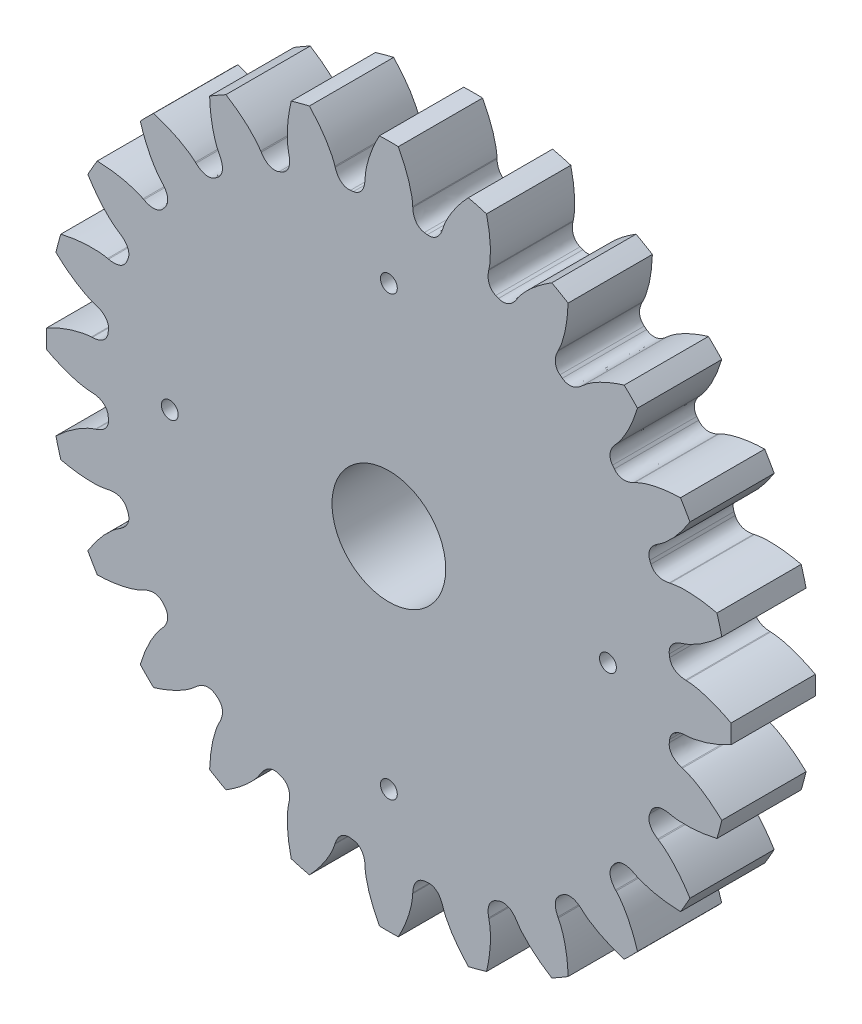
from build123d import *

# Parameters (mm, degrees)
BOSS_EXTRUDE1_DEPTH = 2.54
SKETCH2_R           = 0.254
SKETCH2_R_2         = 1.7145
CUT_EXTRUDE1_DEPTH  = 3.5400001


with BuildPart() as part:
    # Sketch1 → Boss-Extrude1 (new body)
    with BuildSketch(Plane.XY):
        with BuildLine():
            Line((3.016256703, 8.478973751), (3.010500812, 8.452042106))
            add(Edge.make_bspline(
                [(3.010500812, 8.452042106), (3.004237174, 8.425648336), (2.99688827, 8.381281904), (2.991380055, 8.318580234), (2.990974755, 8.26398578), (2.99590325, 8.207108487), (3.008355394, 8.146471227), (3.032122741, 8.081048479), (3.089990682, 7.983054513), (3.163339405, 7.924703305), (3.223040797, 7.900689665)],
                knots=[0, 0, 0, 0, 0.126202457, 0.208952284, 0.292707643, 0.37994875, 0.474167945, 0.579987459, 0.702457265, 1, 1, 1, 1], degree=3))
            ThreePointArc((3.223040797, 7.900689665), (3.265365975, 7.883290824), (3.307597234, 7.865665242))
            add(Edge.make_bspline(
                [(3.307597234, 7.865665242), (3.366792702, 7.84043019), (3.459918616, 7.829825346), (3.570129627, 7.85819873), (3.633196548, 7.887653546), (3.684878561, 7.921725569), (3.728581853, 7.958458917), (3.766899371, 7.997349615), (3.807341251, 8.045581287), (3.833516597, 8.082149552), (3.847750749, 8.105241827)],
                knots=[0, 0, 0, 0, 0.297542735, 0.420012541, 0.525832055, 0.62005125, 0.707292357, 0.791047716, 0.873797543, 1, 1, 1, 1], degree=3))
            Line((3.847750749, 8.105241827), (3.862724269, 8.128355406))
            add(Edge.make_bspline(
                [(3.862724269, 8.128355406), (3.891358957, 8.174937626), (3.947521117, 8.253427702), (4.041920253, 8.3671518), (4.146875377, 8.479989749), (4.278799081, 8.606717556), (4.439552178, 8.744566884), (4.630744241, 8.890618724), (4.792469065, 9.000256315), (4.889939742, 9.0615476), (4.91151267, 9.074890901)],
                knots=[0.278297263, 0.278297263, 0.278297263, 0.278297263, 0.361423458, 0.424900383, 0.502986534, 0.595681913, 0.702986522, 0.82490036, 0.96142343, 1, 1, 1, 1], degree=3))
            ThreePointArc((4.91151267, 9.074890901), (5.159375, 8.936299635), (5.403329722, 8.790940193))
            add(Edge.make_bspline(
                [(5.403329722, 8.790940193), (5.402560548, 8.76558584), (5.398216077, 8.650528115), (5.38412955, 8.455651513), (5.353240977, 8.21704841), (5.314236506, 8.00890748), (5.270448858, 7.831294297), (5.22520589, 7.683981519), (5.1739175, 7.545367421), (5.13402418, 7.457484525), (5.108000138, 7.409395047)],
                knots=[0, 0, 0, 0, 0.03857657, 0.17509964, 0.297013478, 0.404318087, 0.497013466, 0.575099617, 0.638576542, 0.721702737, 0.721702737, 0.721702737, 0.721702737], degree=3))
            Line((5.108000138, 7.409395047), (5.095469951, 7.384870809))
            add(Edge.make_bspline(
                [(5.095469951, 7.384870809), (5.082588531, 7.360997535), (5.064007157, 7.320044888), (5.042458244, 7.260905357), (5.02793667, 7.208276063), (5.017976304, 7.152061229), (5.014310073, 7.090267281), (5.020334915, 7.020922317), (5.050868348, 6.91129009), (5.106615371, 6.835943104), (5.1580673, 6.797295851)],
                knots=[0, 0, 0, 0, 0.126202457, 0.208952284, 0.292707643, 0.37994875, 0.474167945, 0.579987459, 0.702457265, 1, 1, 1, 1], degree=3))
            ThreePointArc((5.1580673, 6.797295851), (5.194447131, 6.769535299), (5.230677558, 6.74158004))
            add(Edge.make_bspline(
                [(5.230677558, 6.74158004), (5.281324677, 6.701883938), (5.368532668, 6.667537684), (5.482331902, 6.666419561), (5.550873337, 6.678547808), (5.609612816, 6.698082566), (5.661334245, 6.72225301), (5.708411779, 6.749901237), (5.75995891, 6.786022326), (5.794706916, 6.81456988), (5.814432772, 6.833191234)],
                knots=[0, 0, 0, 0, 0.297542735, 0.420012541, 0.525832055, 0.62005125, 0.707292357, 0.791047716, 0.873797543, 1, 1, 1, 1], degree=3))
            Line((5.814432772, 6.833191234), (5.834878315, 6.851641805))
            add(Edge.make_bspline(
                [(5.834878315, 6.851641805), (5.874593666, 6.889225572), (5.949156874, 6.950505327), (6.069773399, 7.035922076), (6.200356874, 7.11775078), (6.360584957, 7.206016074), (6.551538557, 7.297562337), (6.774016906, 7.389153435), (6.958607387, 7.453197751), (7.068620183, 7.487173318), (7.092911531, 7.494478473)],
                knots=[0.278297263, 0.278297263, 0.278297263, 0.278297263, 0.361423458, 0.424900383, 0.502986534, 0.595681913, 0.702986522, 0.82490036, 0.96142343, 1, 1, 1, 1], degree=3))
            ThreePointArc((7.092911531, 7.494478473), (7.296458098, 7.296458098), (7.494478473, 7.092911531))
            add(Edge.make_bspline(
                [(7.494478473, 7.092911531), (7.487173318, 7.068620183), (7.453197751, 6.958607387), (7.389153435, 6.774016906), (7.297562337, 6.551538557), (7.206016074, 6.360584957), (7.11775078, 6.200356874), (7.035922076, 6.069773399), (6.950505327, 5.949156874), (6.889225572, 5.874593666), (6.851641805, 5.834878315)],
                knots=[0, 0, 0, 0, 0.03857657, 0.17509964, 0.297013478, 0.404318087, 0.497013466, 0.575099617, 0.638576542, 0.721702737, 0.721702737, 0.721702737, 0.721702737], degree=3))
            Line((6.851641805, 5.834878315), (6.833191234, 5.814432772))
            add(Edge.make_bspline(
                [(6.833191234, 5.814432772), (6.81456988, 5.794706916), (6.786022326, 5.75995891), (6.749901237, 5.708411779), (6.72225301, 5.661334245), (6.698082566, 5.609612816), (6.678547808, 5.550873337), (6.666419561, 5.482331902), (6.667537684, 5.368532668), (6.701883938, 5.281324677), (6.74158004, 5.230677558)],
                knots=[0, 0, 0, 0, 0.126202457, 0.208952284, 0.292707643, 0.37994875, 0.474167945, 0.579987459, 0.702457265, 1, 1, 1, 1], degree=3))
            ThreePointArc((6.74158004, 5.230677558), (6.769535299, 5.194447131), (6.797295851, 5.1580673))
            add(Edge.make_bspline(
                [(6.797295851, 5.1580673), (6.835943104, 5.106615371), (6.91129009, 5.050868348), (7.020922317, 5.020334915), (7.090267281, 5.014310073), (7.152061229, 5.017976304), (7.208276063, 5.02793667), (7.260905357, 5.042458244), (7.320044888, 5.064007157), (7.360997535, 5.082588531), (7.384870809, 5.095469951)],
                knots=[0, 0, 0, 0, 0.297542735, 0.420012541, 0.525832055, 0.62005125, 0.707292357, 0.791047716, 0.873797543, 1, 1, 1, 1], degree=3))
            Line((7.384870809, 5.095469951), (7.409395047, 5.108000138))
            add(Edge.make_bspline(
                [(7.409395047, 5.108000138), (7.457484525, 5.13402418), (7.545367421, 5.1739175), (7.683981519, 5.22520589), (7.831294297, 5.270448858), (8.00890748, 5.314236506), (8.21704841, 5.353240977), (8.455651513, 5.38412955), (8.650528115, 5.398216077), (8.76558584, 5.402560548), (8.790940193, 5.403329722)],
                knots=[0.278297263, 0.278297263, 0.278297263, 0.278297263, 0.361423458, 0.424900383, 0.502986534, 0.595681913, 0.702986522, 0.82490036, 0.96142343, 1, 1, 1, 1], degree=3))
            ThreePointArc((8.790940193, 5.403329722), (8.936299635, 5.159375), (9.074890901, 4.91151267))
            add(Edge.make_bspline(
                [(9.074890901, 4.91151267), (9.0615476, 4.889939742), (9.000256315, 4.792469065), (8.890618724, 4.630744241), (8.744566884, 4.439552178), (8.606717556, 4.278799081), (8.479989749, 4.146875377), (8.3671518, 4.041920253), (8.253427702, 3.947521117), (8.174937626, 3.891358957), (8.128355406, 3.862724269)],
                knots=[0, 0, 0, 0, 0.03857657, 0.17509964, 0.297013478, 0.404318087, 0.497013466, 0.575099617, 0.638576542, 0.721702737, 0.721702737, 0.721702737, 0.721702737], degree=3))
            Line((8.128355406, 3.862724269), (8.105241827, 3.847750749))
            add(Edge.make_bspline(
                [(8.105241827, 3.847750749), (8.082149552, 3.833516597), (8.045581287, 3.807341251), (7.997349615, 3.766899371), (7.958458917, 3.728581853), (7.921725569, 3.684878561), (7.887653546, 3.633196548), (7.85819873, 3.570129627), (7.829825346, 3.459918616), (7.84043019, 3.366792702), (7.865665242, 3.307597234)],
                knots=[0, 0, 0, 0, 0.126202457, 0.208952284, 0.292707643, 0.37994875, 0.474167945, 0.579987459, 0.702457265, 1, 1, 1, 1], degree=3))
            ThreePointArc((7.865665242, 3.307597234), (7.883290824, 3.265365975), (7.900689665, 3.223040797))
            add(Edge.make_bspline(
                [(7.900689665, 3.223040797), (7.924703305, 3.163339405), (7.983054513, 3.089990682), (8.081048479, 3.032122741), (8.146471227, 3.008355394), (8.207108487, 2.99590325), (8.26398578, 2.990974755), (8.318580234, 2.991380055), (8.381281904, 2.99688827), (8.425648336, 3.004237174), (8.452042106, 3.010500812)],
                knots=[0, 0, 0, 0, 0.297542735, 0.420012541, 0.525832055, 0.62005125, 0.707292357, 0.791047716, 0.873797543, 1, 1, 1, 1], degree=3))
            Line((8.452042106, 3.010500812), (8.478973751, 3.016256703))
            add(Edge.make_bspline(
                [(8.478973751, 3.016256703), (8.532160138, 3.028947525), (8.627373647, 3.044735745), (8.774538997, 3.058400557), (8.928541956, 3.063974556), (9.111436193, 3.060300502), (9.322579993, 3.044105091), (9.561047444, 3.012186134), (9.752929647, 2.975354898), (9.865191307, 2.949772205), (9.889880809, 2.94395298)],
                knots=[0.278297263, 0.278297263, 0.278297263, 0.278297263, 0.361423458, 0.424900383, 0.502986534, 0.595681913, 0.702986522, 0.82490036, 0.96142343, 1, 1, 1, 1], degree=3))
            ThreePointArc((9.889880809, 2.94395298), (9.96714712, 2.670689022), (10.036864511, 2.395402336))
            add(Edge.make_bspline(
                [(10.036864511, 2.395402336), (10.018392388, 2.378017989), (9.933962285, 2.299731897), (9.78620304, 2.171894009), (9.595643648, 2.025017655), (9.420885459, 1.905420119), (9.26433143, 1.810791176), (9.128173957, 1.738616921), (8.993892619, 1.67686832), (8.903541191, 1.642934566), (8.851135018, 1.627331947)],
                knots=[0, 0, 0, 0, 0.03857657, 0.17509964, 0.297013478, 0.404318087, 0.497013466, 0.575099617, 0.638576542, 0.721702737, 0.721702737, 0.721702737, 0.721702737], degree=3))
            Line((8.851135018, 1.627331947), (8.824933583, 1.618850872))
            add(Edge.make_bspline(
                [(8.824933583, 1.618850872), (8.798944089, 1.611078457), (8.75684718, 1.595259578), (8.699791833, 1.568678997), (8.652309, 1.54173277), (8.605516067, 1.509025922), (8.55922873, 1.467923419), (8.514454643, 1.414628919), (8.458523349, 1.315516829), (8.444664082, 1.222819367), (8.453718356, 1.159109625)],
                knots=[0, 0, 0, 0, 0.126202457, 0.208952284, 0.292707643, 0.37994875, 0.474167945, 0.579987459, 0.702457265, 1, 1, 1, 1], degree=3))
            ThreePointArc((8.453718356, 1.159109625), (8.459813106, 1.113755525), (8.465664534, 1.068369391))
            add(Edge.make_bspline(
                [(8.465664534, 1.068369391), (8.473408072, 1.004487086), (8.510786965, 0.918535256), (8.590464542, 0.837276413), (8.647506621, 0.797386265), (8.702854865, 0.769664341), (8.756518523, 0.750182853), (8.809357615, 0.736444258), (8.871348409, 0.725536399), (8.916105128, 0.721152018), (8.9432207, 0.720371017)],
                knots=[0, 0, 0, 0, 0.297542735, 0.420012541, 0.525832055, 0.62005125, 0.707292357, 0.791047716, 0.873797543, 1, 1, 1, 1], degree=3))
            Line((8.9432207, 0.720371017), (8.970724407, 0.718960358))
            add(Edge.make_bspline(
                [(8.970724407, 0.718960358), (9.025383137, 0.717453101), (9.121438617, 0.708060281), (9.267126143, 0.683170281), (9.417324235, 0.648695452), (9.593035587, 0.597810076), (9.792793155, 0.527518474), (10.014873791, 0.434967211), (10.190685142, 0.3497282), (10.29250029, 0.29596176), (10.314842391, 0.283950707)],
                knots=[0.278297263, 0.278297263, 0.278297263, 0.278297263, 0.361423458, 0.424900383, 0.502986534, 0.595681913, 0.702986522, 0.82490036, 0.96142343, 1, 1, 1, 1], degree=3))
            ThreePointArc((10.314842391, 0.283950707), (10.31875, 0), (10.314842391, -0.283950707))
            add(Edge.make_bspline(
                [(10.314842391, -0.283950707), (10.29250029, -0.29596176), (10.190685142, -0.3497282), (10.014873791, -0.434967211), (9.792793155, -0.527518474), (9.593035587, -0.597810076), (9.417324235, -0.648695452), (9.267126143, -0.683170281), (9.121438617, -0.708060281), (9.025383137, -0.717453101), (8.970724407, -0.718960358)],
                knots=[0, 0, 0, 0, 0.03857657, 0.17509964, 0.297013478, 0.404318087, 0.497013466, 0.575099617, 0.638576542, 0.721702737, 0.721702737, 0.721702737, 0.721702737], degree=3))
            Line((8.970724407, -0.718960358), (8.9432207, -0.720371017))
            add(Edge.make_bspline(
                [(8.9432207, -0.720371017), (8.916105128, -0.721152018), (8.871348409, -0.725536399), (8.809357615, -0.736444258), (8.756518523, -0.750182853), (8.702854865, -0.769664341), (8.647506621, -0.797386265), (8.590464542, -0.837276413), (8.510786965, -0.918535256), (8.473408072, -1.004487086), (8.465664534, -1.068369391)],
                knots=[0, 0, 0, 0, 0.126202457, 0.208952284, 0.292707643, 0.37994875, 0.474167945, 0.579987459, 0.702457265, 1, 1, 1, 1], degree=3))
            ThreePointArc((8.465664534, -1.068369391), (8.459813106, -1.113755525), (8.453718356, -1.159109625))
            add(Edge.make_bspline(
                [(8.453718356, -1.159109625), (8.444664082, -1.222819367), (8.458523349, -1.315516829), (8.514454643, -1.414628919), (8.55922873, -1.467923419), (8.605516067, -1.509025922), (8.652309, -1.54173277), (8.699791833, -1.568678997), (8.75684718, -1.595259578), (8.798944089, -1.611078457), (8.824933583, -1.618850872)],
                knots=[0, 0, 0, 0, 0.297542735, 0.420012541, 0.525832055, 0.62005125, 0.707292357, 0.791047716, 0.873797543, 1, 1, 1, 1], degree=3))
            Line((8.824933583, -1.618850872), (8.851135018, -1.627331947))
            add(Edge.make_bspline(
                [(8.851135018, -1.627331947), (8.903541191, -1.642934566), (8.993892619, -1.67686832), (9.128173957, -1.738616921), (9.26433143, -1.810791176), (9.420885459, -1.905420119), (9.595643648, -2.025017655), (9.78620304, -2.171894009), (9.933962285, -2.299731897), (10.018392388, -2.378017989), (10.036864511, -2.395402336)],
                knots=[0.278297263, 0.278297263, 0.278297263, 0.278297263, 0.361423458, 0.424900383, 0.502986534, 0.595681913, 0.702986522, 0.82490036, 0.96142343, 1, 1, 1, 1], degree=3))
            ThreePointArc((10.036864511, -2.395402336), (9.96714712, -2.670689022), (9.889880809, -2.94395298))
            add(Edge.make_bspline(
                [(9.889880809, -2.94395298), (9.865191307, -2.949772205), (9.752929647, -2.975354898), (9.561047444, -3.012186134), (9.322579993, -3.044105091), (9.111436193, -3.060300502), (8.928541956, -3.063974556), (8.774538997, -3.058400557), (8.627373647, -3.044735745), (8.532160138, -3.028947525), (8.478973751, -3.016256703)],
                knots=[0, 0, 0, 0, 0.03857657, 0.17509964, 0.297013478, 0.404318087, 0.497013466, 0.575099617, 0.638576542, 0.721702737, 0.721702737, 0.721702737, 0.721702737], degree=3))
            Line((8.478973751, -3.016256703), (8.452042106, -3.010500812))
            add(Edge.make_bspline(
                [(8.452042106, -3.010500812), (8.425648336, -3.004237174), (8.381281904, -2.99688827), (8.318580234, -2.991380055), (8.26398578, -2.990974755), (8.207108487, -2.99590325), (8.146471227, -3.008355394), (8.081048479, -3.032122741), (7.983054513, -3.089990682), (7.924703305, -3.163339405), (7.900689665, -3.223040797)],
                knots=[0, 0, 0, 0, 0.126202457, 0.208952284, 0.292707643, 0.37994875, 0.474167945, 0.579987459, 0.702457265, 1, 1, 1, 1], degree=3))
            ThreePointArc((7.900689665, -3.223040797), (7.883290824, -3.265365975), (7.865665242, -3.307597234))
            add(Edge.make_bspline(
                [(7.865665242, -3.307597234), (7.84043019, -3.366792702), (7.829825346, -3.459918616), (7.85819873, -3.570129627), (7.887653546, -3.633196548), (7.921725569, -3.684878561), (7.958458917, -3.728581853), (7.997349615, -3.766899371), (8.045581287, -3.807341251), (8.082149552, -3.833516597), (8.105241827, -3.847750749)],
                knots=[0, 0, 0, 0, 0.297542735, 0.420012541, 0.525832055, 0.62005125, 0.707292357, 0.791047716, 0.873797543, 1, 1, 1, 1], degree=3))
            Line((8.105241827, -3.847750749), (8.128355406, -3.862724269))
            add(Edge.make_bspline(
                [(8.128355406, -3.862724269), (8.174937626, -3.891358957), (8.253427702, -3.947521117), (8.3671518, -4.041920253), (8.479989749, -4.146875377), (8.606717556, -4.278799081), (8.744566884, -4.439552178), (8.890618724, -4.630744241), (9.000256315, -4.792469065), (9.0615476, -4.889939742), (9.074890901, -4.91151267)],
                knots=[0.278297263, 0.278297263, 0.278297263, 0.278297263, 0.361423458, 0.424900383, 0.502986534, 0.595681913, 0.702986522, 0.82490036, 0.96142343, 1, 1, 1, 1], degree=3))
            ThreePointArc((9.074890901, -4.91151267), (8.936299635, -5.159375), (8.790940193, -5.403329722))
            add(Edge.make_bspline(
                [(8.790940193, -5.403329722), (8.76558584, -5.402560548), (8.650528115, -5.398216077), (8.455651513, -5.38412955), (8.21704841, -5.353240977), (8.00890748, -5.314236506), (7.831294297, -5.270448858), (7.683981519, -5.22520589), (7.545367421, -5.1739175), (7.457484525, -5.13402418), (7.409395047, -5.108000138)],
                knots=[0, 0, 0, 0, 0.03857657, 0.17509964, 0.297013478, 0.404318087, 0.497013466, 0.575099617, 0.638576542, 0.721702737, 0.721702737, 0.721702737, 0.721702737], degree=3))
            Line((7.409395047, -5.108000138), (7.384870809, -5.095469951))
            add(Edge.make_bspline(
                [(7.384870809, -5.095469951), (7.360997535, -5.082588531), (7.320044888, -5.064007157), (7.260905357, -5.042458244), (7.208276063, -5.02793667), (7.152061229, -5.017976304), (7.090267281, -5.014310073), (7.020922317, -5.020334915), (6.91129009, -5.050868348), (6.835943104, -5.106615371), (6.797295851, -5.1580673)],
                knots=[0, 0, 0, 0, 0.126202457, 0.208952284, 0.292707643, 0.37994875, 0.474167945, 0.579987459, 0.702457265, 1, 1, 1, 1], degree=3))
            ThreePointArc((6.797295851, -5.1580673), (6.769535299, -5.194447131), (6.74158004, -5.230677558))
            add(Edge.make_bspline(
                [(6.74158004, -5.230677558), (6.701883938, -5.281324677), (6.667537684, -5.368532668), (6.666419561, -5.482331902), (6.678547808, -5.550873337), (6.698082566, -5.609612816), (6.72225301, -5.661334245), (6.749901237, -5.708411779), (6.786022326, -5.75995891), (6.81456988, -5.794706916), (6.833191234, -5.814432772)],
                knots=[0, 0, 0, 0, 0.297542735, 0.420012541, 0.525832055, 0.62005125, 0.707292357, 0.791047716, 0.873797543, 1, 1, 1, 1], degree=3))
            Line((6.833191234, -5.814432772), (6.851641805, -5.834878315))
            add(Edge.make_bspline(
                [(6.851641805, -5.834878315), (6.889225572, -5.874593666), (6.950505327, -5.949156874), (7.035922076, -6.069773399), (7.11775078, -6.200356874), (7.206016074, -6.360584957), (7.297562337, -6.551538557), (7.389153435, -6.774016906), (7.453197751, -6.958607387), (7.487173318, -7.068620183), (7.494478473, -7.092911531)],
                knots=[0.278297263, 0.278297263, 0.278297263, 0.278297263, 0.361423458, 0.424900383, 0.502986534, 0.595681913, 0.702986522, 0.82490036, 0.96142343, 1, 1, 1, 1], degree=3))
            ThreePointArc((7.494478473, -7.092911531), (7.296458098, -7.296458098), (7.092911531, -7.494478473))
            add(Edge.make_bspline(
                [(7.092911531, -7.494478473), (7.068620183, -7.487173318), (6.958607387, -7.453197751), (6.774016906, -7.389153435), (6.551538557, -7.297562337), (6.360584957, -7.206016074), (6.200356874, -7.11775078), (6.069773399, -7.035922076), (5.949156874, -6.950505327), (5.874593666, -6.889225572), (5.834878315, -6.851641805)],
                knots=[0, 0, 0, 0, 0.03857657, 0.17509964, 0.297013478, 0.404318087, 0.497013466, 0.575099617, 0.638576542, 0.721702737, 0.721702737, 0.721702737, 0.721702737], degree=3))
            Line((5.834878315, -6.851641805), (5.814432772, -6.833191234))
            add(Edge.make_bspline(
                [(5.814432772, -6.833191234), (5.794706916, -6.81456988), (5.75995891, -6.786022326), (5.708411779, -6.749901237), (5.661334245, -6.72225301), (5.609612816, -6.698082566), (5.550873337, -6.678547808), (5.482331902, -6.666419561), (5.368532668, -6.667537684), (5.281324677, -6.701883938), (5.230677558, -6.74158004)],
                knots=[0, 0, 0, 0, 0.126202457, 0.208952284, 0.292707643, 0.37994875, 0.474167945, 0.579987459, 0.702457265, 1, 1, 1, 1], degree=3))
            ThreePointArc((5.230677558, -6.74158004), (5.194447131, -6.769535299), (5.1580673, -6.797295851))
            add(Edge.make_bspline(
                [(5.1580673, -6.797295851), (5.106615371, -6.835943104), (5.050868348, -6.91129009), (5.020334915, -7.020922317), (5.014310073, -7.090267281), (5.017976304, -7.152061229), (5.02793667, -7.208276063), (5.042458244, -7.260905357), (5.064007157, -7.320044888), (5.082588531, -7.360997535), (5.095469951, -7.384870809)],
                knots=[0, 0, 0, 0, 0.297542735, 0.420012541, 0.525832055, 0.62005125, 0.707292357, 0.791047716, 0.873797543, 1, 1, 1, 1], degree=3))
            Line((5.095469951, -7.384870809), (5.108000138, -7.409395047))
            add(Edge.make_bspline(
                [(5.108000138, -7.409395047), (5.13402418, -7.457484525), (5.1739175, -7.545367421), (5.22520589, -7.683981519), (5.270448858, -7.831294297), (5.314236506, -8.00890748), (5.353240977, -8.21704841), (5.38412955, -8.455651513), (5.398216077, -8.650528115), (5.402560548, -8.76558584), (5.403329722, -8.790940193)],
                knots=[0.278297263, 0.278297263, 0.278297263, 0.278297263, 0.361423458, 0.424900383, 0.502986534, 0.595681913, 0.702986522, 0.82490036, 0.96142343, 1, 1, 1, 1], degree=3))
            ThreePointArc((5.403329722, -8.790940193), (5.159375, -8.936299635), (4.91151267, -9.074890901))
            add(Edge.make_bspline(
                [(4.91151267, -9.074890901), (4.889939742, -9.0615476), (4.792469065, -9.000256315), (4.630744241, -8.890618724), (4.439552178, -8.744566884), (4.278799081, -8.606717556), (4.146875377, -8.479989749), (4.041920253, -8.3671518), (3.947521117, -8.253427702), (3.891358957, -8.174937626), (3.862724269, -8.128355406)],
                knots=[0, 0, 0, 0, 0.03857657, 0.17509964, 0.297013478, 0.404318087, 0.497013466, 0.575099617, 0.638576542, 0.721702737, 0.721702737, 0.721702737, 0.721702737], degree=3))
            Line((3.862724269, -8.128355406), (3.847750749, -8.105241827))
            add(Edge.make_bspline(
                [(3.847750749, -8.105241827), (3.833516597, -8.082149552), (3.807341251, -8.045581287), (3.766899371, -7.997349615), (3.728581853, -7.958458917), (3.684878561, -7.921725569), (3.633196548, -7.887653546), (3.570129627, -7.85819873), (3.459918616, -7.829825346), (3.366792702, -7.84043019), (3.307597234, -7.865665242)],
                knots=[0, 0, 0, 0, 0.126202457, 0.208952284, 0.292707643, 0.37994875, 0.474167945, 0.579987459, 0.702457265, 1, 1, 1, 1], degree=3))
            ThreePointArc((3.307597234, -7.865665242), (3.265365975, -7.883290824), (3.223040797, -7.900689665))
            add(Edge.make_bspline(
                [(3.223040797, -7.900689665), (3.163339405, -7.924703305), (3.089990682, -7.983054513), (3.032122741, -8.081048479), (3.008355394, -8.146471227), (2.99590325, -8.207108487), (2.990974755, -8.26398578), (2.991380055, -8.318580234), (2.99688827, -8.381281904), (3.004237174, -8.425648336), (3.010500812, -8.452042106)],
                knots=[0, 0, 0, 0, 0.297542735, 0.420012541, 0.525832055, 0.62005125, 0.707292357, 0.791047716, 0.873797543, 1, 1, 1, 1], degree=3))
            Line((3.010500812, -8.452042106), (3.016256703, -8.478973751))
            add(Edge.make_bspline(
                [(3.016256703, -8.478973751), (3.028947525, -8.532160138), (3.044735745, -8.627373647), (3.058400557, -8.774538997), (3.063974556, -8.928541956), (3.060300502, -9.111436193), (3.044105091, -9.322579993), (3.012186134, -9.561047444), (2.975354898, -9.752929647), (2.949772205, -9.865191307), (2.94395298, -9.889880809)],
                knots=[0.278297263, 0.278297263, 0.278297263, 0.278297263, 0.361423458, 0.424900383, 0.502986534, 0.595681913, 0.702986522, 0.82490036, 0.96142343, 1, 1, 1, 1], degree=3))
            ThreePointArc((2.94395298, -9.889880809), (2.670689022, -9.96714712), (2.395402336, -10.036864511))
            add(Edge.make_bspline(
                [(2.395402336, -10.036864511), (2.378017989, -10.018392388), (2.299731897, -9.933962285), (2.171894009, -9.78620304), (2.025017655, -9.595643648), (1.905420119, -9.420885459), (1.810791176, -9.26433143), (1.738616921, -9.128173957), (1.67686832, -8.993892619), (1.642934566, -8.903541191), (1.627331947, -8.851135018)],
                knots=[0, 0, 0, 0, 0.03857657, 0.17509964, 0.297013478, 0.404318087, 0.497013466, 0.575099617, 0.638576542, 0.721702737, 0.721702737, 0.721702737, 0.721702737], degree=3))
            Line((1.627331947, -8.851135018), (1.618850872, -8.824933583))
            add(Edge.make_bspline(
                [(1.618850872, -8.824933583), (1.611078457, -8.798944089), (1.595259578, -8.75684718), (1.568678997, -8.699791833), (1.54173277, -8.652309), (1.509025922, -8.605516067), (1.467923419, -8.55922873), (1.414628919, -8.514454643), (1.315516829, -8.458523349), (1.222819367, -8.444664082), (1.159109625, -8.453718356)],
                knots=[0, 0, 0, 0, 0.126202457, 0.208952284, 0.292707643, 0.37994875, 0.474167945, 0.579987459, 0.702457265, 1, 1, 1, 1], degree=3))
            ThreePointArc((1.159109625, -8.453718356), (1.113755525, -8.459813106), (1.068369391, -8.465664534))
            add(Edge.make_bspline(
                [(1.068369391, -8.465664534), (1.004487086, -8.473408072), (0.918535256, -8.510786965), (0.837276413, -8.590464542), (0.797386265, -8.647506621), (0.769664341, -8.702854865), (0.750182853, -8.756518523), (0.736444258, -8.809357615), (0.725536399, -8.871348409), (0.721152018, -8.916105128), (0.720371017, -8.9432207)],
                knots=[0, 0, 0, 0, 0.297542735, 0.420012541, 0.525832055, 0.62005125, 0.707292357, 0.791047716, 0.873797543, 1, 1, 1, 1], degree=3))
            Line((0.720371017, -8.9432207), (0.718960358, -8.970724407))
            add(Edge.make_bspline(
                [(0.718960358, -8.970724407), (0.717453101, -9.025383137), (0.708060281, -9.121438617), (0.683170281, -9.267126143), (0.648695452, -9.417324235), (0.597810076, -9.593035587), (0.527518474, -9.792793155), (0.434967211, -10.014873791), (0.3497282, -10.190685142), (0.29596176, -10.29250029), (0.283950707, -10.314842391)],
                knots=[0.278297263, 0.278297263, 0.278297263, 0.278297263, 0.361423458, 0.424900383, 0.502986534, 0.595681913, 0.702986522, 0.82490036, 0.96142343, 1, 1, 1, 1], degree=3))
            ThreePointArc((0.283950707, -10.314842391), (0, -10.31875), (-0.283950707, -10.314842391))
            add(Edge.make_bspline(
                [(-0.283950707, -10.314842391), (-0.29596176, -10.29250029), (-0.3497282, -10.190685142), (-0.434967211, -10.014873791), (-0.527518474, -9.792793155), (-0.597810076, -9.593035587), (-0.648695452, -9.417324235), (-0.683170281, -9.267126143), (-0.708060281, -9.121438617), (-0.717453101, -9.025383137), (-0.718960358, -8.970724407)],
                knots=[0, 0, 0, 0, 0.03857657, 0.17509964, 0.297013478, 0.404318087, 0.497013466, 0.575099617, 0.638576542, 0.721702737, 0.721702737, 0.721702737, 0.721702737], degree=3))
            Line((-0.718960358, -8.970724407), (-0.720371017, -8.9432207))
            add(Edge.make_bspline(
                [(-0.720371017, -8.9432207), (-0.721152018, -8.916105128), (-0.725536399, -8.871348409), (-0.736444258, -8.809357615), (-0.750182853, -8.756518523), (-0.769664341, -8.702854865), (-0.797386265, -8.647506621), (-0.837276413, -8.590464542), (-0.918535256, -8.510786965), (-1.004487086, -8.473408072), (-1.068369391, -8.465664534)],
                knots=[0, 0, 0, 0, 0.126202457, 0.208952284, 0.292707643, 0.37994875, 0.474167945, 0.579987459, 0.702457265, 1, 1, 1, 1], degree=3))
            ThreePointArc((-1.068369391, -8.465664534), (-1.113755525, -8.459813106), (-1.159109625, -8.453718356))
            add(Edge.make_bspline(
                [(-1.159109625, -8.453718356), (-1.222819367, -8.444664082), (-1.315516829, -8.458523349), (-1.414628919, -8.514454643), (-1.467923419, -8.55922873), (-1.509025922, -8.605516067), (-1.54173277, -8.652309), (-1.568678997, -8.699791833), (-1.595259578, -8.75684718), (-1.611078457, -8.798944089), (-1.618850872, -8.824933583)],
                knots=[0, 0, 0, 0, 0.297542735, 0.420012541, 0.525832055, 0.62005125, 0.707292357, 0.791047716, 0.873797543, 1, 1, 1, 1], degree=3))
            Line((-1.618850872, -8.824933583), (-1.627331947, -8.851135018))
            add(Edge.make_bspline(
                [(-1.627331947, -8.851135018), (-1.642934566, -8.903541191), (-1.67686832, -8.993892619), (-1.738616921, -9.128173957), (-1.810791176, -9.26433143), (-1.905420119, -9.420885459), (-2.025017655, -9.595643648), (-2.171894009, -9.78620304), (-2.299731897, -9.933962285), (-2.378017989, -10.018392388), (-2.395402336, -10.036864511)],
                knots=[0.278297263, 0.278297263, 0.278297263, 0.278297263, 0.361423458, 0.424900383, 0.502986534, 0.595681913, 0.702986522, 0.82490036, 0.96142343, 1, 1, 1, 1], degree=3))
            ThreePointArc((-2.395402336, -10.036864511), (-2.670689022, -9.96714712), (-2.94395298, -9.889880809))
            add(Edge.make_bspline(
                [(-2.94395298, -9.889880809), (-2.949772205, -9.865191307), (-2.975354898, -9.752929647), (-3.012186134, -9.561047444), (-3.044105091, -9.322579993), (-3.060300502, -9.111436193), (-3.063974556, -8.928541956), (-3.058400557, -8.774538997), (-3.044735745, -8.627373647), (-3.028947525, -8.532160138), (-3.016256703, -8.478973751)],
                knots=[0, 0, 0, 0, 0.03857657, 0.17509964, 0.297013478, 0.404318087, 0.497013466, 0.575099617, 0.638576542, 0.721702737, 0.721702737, 0.721702737, 0.721702737], degree=3))
            Line((-3.016256703, -8.478973751), (-3.010500812, -8.452042106))
            add(Edge.make_bspline(
                [(-3.010500812, -8.452042106), (-3.004237174, -8.425648336), (-2.99688827, -8.381281904), (-2.991380055, -8.318580234), (-2.990974755, -8.26398578), (-2.99590325, -8.207108487), (-3.008355394, -8.146471227), (-3.032122741, -8.081048479), (-3.089990682, -7.983054513), (-3.163339405, -7.924703305), (-3.223040797, -7.900689665)],
                knots=[0, 0, 0, 0, 0.126202457, 0.208952284, 0.292707643, 0.37994875, 0.474167945, 0.579987459, 0.702457265, 1, 1, 1, 1], degree=3))
            ThreePointArc((-3.223040797, -7.900689665), (-3.265365975, -7.883290824), (-3.307597234, -7.865665242))
            add(Edge.make_bspline(
                [(-3.307597234, -7.865665242), (-3.366792702, -7.84043019), (-3.459918616, -7.829825346), (-3.570129627, -7.85819873), (-3.633196548, -7.887653546), (-3.684878561, -7.921725569), (-3.728581853, -7.958458917), (-3.766899371, -7.997349615), (-3.807341251, -8.045581287), (-3.833516597, -8.082149552), (-3.847750749, -8.105241827)],
                knots=[0, 0, 0, 0, 0.297542735, 0.420012541, 0.525832055, 0.62005125, 0.707292357, 0.791047716, 0.873797543, 1, 1, 1, 1], degree=3))
            Line((-3.847750749, -8.105241827), (-3.862724269, -8.128355406))
            add(Edge.make_bspline(
                [(-3.862724269, -8.128355406), (-3.891358957, -8.174937626), (-3.947521117, -8.253427702), (-4.041920253, -8.3671518), (-4.146875377, -8.479989749), (-4.278799081, -8.606717556), (-4.439552178, -8.744566884), (-4.630744241, -8.890618724), (-4.792469065, -9.000256315), (-4.889939742, -9.0615476), (-4.91151267, -9.074890901)],
                knots=[0.278297263, 0.278297263, 0.278297263, 0.278297263, 0.361423458, 0.424900383, 0.502986534, 0.595681913, 0.702986522, 0.82490036, 0.96142343, 1, 1, 1, 1], degree=3))
            ThreePointArc((-4.91151267, -9.074890901), (-5.159375, -8.936299635), (-5.403329722, -8.790940193))
            add(Edge.make_bspline(
                [(-5.403329722, -8.790940193), (-5.402560548, -8.76558584), (-5.398216077, -8.650528115), (-5.38412955, -8.455651513), (-5.353240977, -8.21704841), (-5.314236506, -8.00890748), (-5.270448858, -7.831294297), (-5.22520589, -7.683981519), (-5.1739175, -7.545367421), (-5.13402418, -7.457484525), (-5.108000138, -7.409395047)],
                knots=[0, 0, 0, 0, 0.03857657, 0.17509964, 0.297013478, 0.404318087, 0.497013466, 0.575099617, 0.638576542, 0.721702737, 0.721702737, 0.721702737, 0.721702737], degree=3))
            Line((-5.108000138, -7.409395047), (-5.095469951, -7.384870809))
            add(Edge.make_bspline(
                [(-5.095469951, -7.384870809), (-5.082588531, -7.360997535), (-5.064007157, -7.320044888), (-5.042458244, -7.260905357), (-5.02793667, -7.208276063), (-5.017976304, -7.152061229), (-5.014310073, -7.090267281), (-5.020334915, -7.020922317), (-5.050868348, -6.91129009), (-5.106615371, -6.835943104), (-5.1580673, -6.797295851)],
                knots=[0, 0, 0, 0, 0.126202457, 0.208952284, 0.292707643, 0.37994875, 0.474167945, 0.579987459, 0.702457265, 1, 1, 1, 1], degree=3))
            ThreePointArc((-5.1580673, -6.797295851), (-5.194447131, -6.769535299), (-5.230677558, -6.74158004))
            add(Edge.make_bspline(
                [(-5.230677558, -6.74158004), (-5.281324677, -6.701883938), (-5.368532668, -6.667537684), (-5.482331902, -6.666419561), (-5.550873337, -6.678547808), (-5.609612816, -6.698082566), (-5.661334245, -6.72225301), (-5.708411779, -6.749901237), (-5.75995891, -6.786022326), (-5.794706916, -6.81456988), (-5.814432772, -6.833191234)],
                knots=[0, 0, 0, 0, 0.297542735, 0.420012541, 0.525832055, 0.62005125, 0.707292357, 0.791047716, 0.873797543, 1, 1, 1, 1], degree=3))
            Line((-5.814432772, -6.833191234), (-5.834878315, -6.851641805))
            add(Edge.make_bspline(
                [(-5.834878315, -6.851641805), (-5.874593666, -6.889225572), (-5.949156874, -6.950505327), (-6.069773399, -7.035922076), (-6.200356874, -7.11775078), (-6.360584957, -7.206016074), (-6.551538557, -7.297562337), (-6.774016906, -7.389153435), (-6.958607387, -7.453197751), (-7.068620183, -7.487173318), (-7.092911531, -7.494478473)],
                knots=[0.278297263, 0.278297263, 0.278297263, 0.278297263, 0.361423458, 0.424900383, 0.502986534, 0.595681913, 0.702986522, 0.82490036, 0.96142343, 1, 1, 1, 1], degree=3))
            ThreePointArc((-7.092911531, -7.494478473), (-7.296458098, -7.296458098), (-7.494478473, -7.092911531))
            add(Edge.make_bspline(
                [(-7.494478473, -7.092911531), (-7.487173318, -7.068620183), (-7.453197751, -6.958607387), (-7.389153435, -6.774016906), (-7.297562337, -6.551538557), (-7.206016074, -6.360584957), (-7.11775078, -6.200356874), (-7.035922076, -6.069773399), (-6.950505327, -5.949156874), (-6.889225572, -5.874593666), (-6.851641805, -5.834878315)],
                knots=[0, 0, 0, 0, 0.03857657, 0.17509964, 0.297013478, 0.404318087, 0.497013466, 0.575099617, 0.638576542, 0.721702737, 0.721702737, 0.721702737, 0.721702737], degree=3))
            Line((-6.851641805, -5.834878315), (-6.833191234, -5.814432772))
            add(Edge.make_bspline(
                [(-6.833191234, -5.814432772), (-6.81456988, -5.794706916), (-6.786022326, -5.75995891), (-6.749901237, -5.708411779), (-6.72225301, -5.661334245), (-6.698082566, -5.609612816), (-6.678547808, -5.550873337), (-6.666419561, -5.482331902), (-6.667537684, -5.368532668), (-6.701883938, -5.281324677), (-6.74158004, -5.230677558)],
                knots=[0, 0, 0, 0, 0.126202457, 0.208952284, 0.292707643, 0.37994875, 0.474167945, 0.579987459, 0.702457265, 1, 1, 1, 1], degree=3))
            ThreePointArc((-6.74158004, -5.230677558), (-6.769535299, -5.194447131), (-6.797295851, -5.1580673))
            add(Edge.make_bspline(
                [(-6.797295851, -5.1580673), (-6.835943104, -5.106615371), (-6.91129009, -5.050868348), (-7.020922317, -5.020334915), (-7.090267281, -5.014310073), (-7.152061229, -5.017976304), (-7.208276063, -5.02793667), (-7.260905357, -5.042458244), (-7.320044888, -5.064007157), (-7.360997535, -5.082588531), (-7.384870809, -5.095469951)],
                knots=[0, 0, 0, 0, 0.297542735, 0.420012541, 0.525832055, 0.62005125, 0.707292357, 0.791047716, 0.873797543, 1, 1, 1, 1], degree=3))
            Line((-7.384870809, -5.095469951), (-7.409395047, -5.108000138))
            add(Edge.make_bspline(
                [(-7.409395047, -5.108000138), (-7.457484525, -5.13402418), (-7.545367421, -5.1739175), (-7.683981519, -5.22520589), (-7.831294297, -5.270448858), (-8.00890748, -5.314236506), (-8.21704841, -5.353240977), (-8.455651513, -5.38412955), (-8.650528115, -5.398216077), (-8.76558584, -5.402560548), (-8.790940193, -5.403329722)],
                knots=[0.278297263, 0.278297263, 0.278297263, 0.278297263, 0.361423458, 0.424900383, 0.502986534, 0.595681913, 0.702986522, 0.82490036, 0.96142343, 1, 1, 1, 1], degree=3))
            ThreePointArc((-8.790940193, -5.403329722), (-8.936299635, -5.159375), (-9.074890901, -4.91151267))
            add(Edge.make_bspline(
                [(-9.074890901, -4.91151267), (-9.0615476, -4.889939742), (-9.000256315, -4.792469065), (-8.890618724, -4.630744241), (-8.744566884, -4.439552178), (-8.606717556, -4.278799081), (-8.479989749, -4.146875377), (-8.3671518, -4.041920253), (-8.253427702, -3.947521117), (-8.174937626, -3.891358957), (-8.128355406, -3.862724269)],
                knots=[0, 0, 0, 0, 0.03857657, 0.17509964, 0.297013478, 0.404318087, 0.497013466, 0.575099617, 0.638576542, 0.721702737, 0.721702737, 0.721702737, 0.721702737], degree=3))
            Line((-8.128355406, -3.862724269), (-8.105241827, -3.847750749))
            add(Edge.make_bspline(
                [(-8.105241827, -3.847750749), (-8.082149552, -3.833516597), (-8.045581287, -3.807341251), (-7.997349615, -3.766899371), (-7.958458917, -3.728581853), (-7.921725569, -3.684878561), (-7.887653546, -3.633196548), (-7.85819873, -3.570129627), (-7.829825346, -3.459918616), (-7.84043019, -3.366792702), (-7.865665242, -3.307597234)],
                knots=[0, 0, 0, 0, 0.126202457, 0.208952284, 0.292707643, 0.37994875, 0.474167945, 0.579987459, 0.702457265, 1, 1, 1, 1], degree=3))
            ThreePointArc((-7.865665242, -3.307597234), (-7.883290824, -3.265365975), (-7.900689665, -3.223040797))
            add(Edge.make_bspline(
                [(-7.900689665, -3.223040797), (-7.924703305, -3.163339405), (-7.983054513, -3.089990682), (-8.081048479, -3.032122741), (-8.146471227, -3.008355394), (-8.207108487, -2.99590325), (-8.26398578, -2.990974755), (-8.318580234, -2.991380055), (-8.381281904, -2.99688827), (-8.425648336, -3.004237174), (-8.452042106, -3.010500812)],
                knots=[0, 0, 0, 0, 0.297542735, 0.420012541, 0.525832055, 0.62005125, 0.707292357, 0.791047716, 0.873797543, 1, 1, 1, 1], degree=3))
            Line((-8.452042106, -3.010500812), (-8.478973751, -3.016256703))
            add(Edge.make_bspline(
                [(-8.478973751, -3.016256703), (-8.532160138, -3.028947525), (-8.627373647, -3.044735745), (-8.774538997, -3.058400557), (-8.928541956, -3.063974556), (-9.111436193, -3.060300502), (-9.322579993, -3.044105091), (-9.561047444, -3.012186134), (-9.752929647, -2.975354898), (-9.865191307, -2.949772205), (-9.889880809, -2.94395298)],
                knots=[0.278297263, 0.278297263, 0.278297263, 0.278297263, 0.361423458, 0.424900383, 0.502986534, 0.595681913, 0.702986522, 0.82490036, 0.96142343, 1, 1, 1, 1], degree=3))
            ThreePointArc((-9.889880809, -2.94395298), (-9.96714712, -2.670689022), (-10.036864511, -2.395402336))
            add(Edge.make_bspline(
                [(-10.036864511, -2.395402336), (-10.018392388, -2.378017989), (-9.933962285, -2.299731897), (-9.78620304, -2.171894009), (-9.595643648, -2.025017655), (-9.420885459, -1.905420119), (-9.26433143, -1.810791176), (-9.128173957, -1.738616921), (-8.993892619, -1.67686832), (-8.903541191, -1.642934566), (-8.851135018, -1.627331947)],
                knots=[0, 0, 0, 0, 0.03857657, 0.17509964, 0.297013478, 0.404318087, 0.497013466, 0.575099617, 0.638576542, 0.721702737, 0.721702737, 0.721702737, 0.721702737], degree=3))
            Line((-8.851135018, -1.627331947), (-8.824933583, -1.618850872))
            add(Edge.make_bspline(
                [(-8.824933583, -1.618850872), (-8.798944089, -1.611078457), (-8.75684718, -1.595259578), (-8.699791833, -1.568678997), (-8.652309, -1.54173277), (-8.605516067, -1.509025922), (-8.55922873, -1.467923419), (-8.514454643, -1.414628919), (-8.458523349, -1.315516829), (-8.444664082, -1.222819367), (-8.453718356, -1.159109625)],
                knots=[0, 0, 0, 0, 0.126202457, 0.208952284, 0.292707643, 0.37994875, 0.474167945, 0.579987459, 0.702457265, 1, 1, 1, 1], degree=3))
            ThreePointArc((-8.453718356, -1.159109625), (-8.459813106, -1.113755525), (-8.465664534, -1.068369391))
            add(Edge.make_bspline(
                [(-8.465664534, -1.068369391), (-8.473408072, -1.004487086), (-8.510786965, -0.918535256), (-8.590464542, -0.837276413), (-8.647506621, -0.797386265), (-8.702854865, -0.769664341), (-8.756518523, -0.750182853), (-8.809357615, -0.736444258), (-8.871348409, -0.725536399), (-8.916105128, -0.721152018), (-8.9432207, -0.720371017)],
                knots=[0, 0, 0, 0, 0.297542735, 0.420012541, 0.525832055, 0.62005125, 0.707292357, 0.791047716, 0.873797543, 1, 1, 1, 1], degree=3))
            Line((-8.9432207, -0.720371017), (-8.970724407, -0.718960358))
            add(Edge.make_bspline(
                [(-8.970724407, -0.718960358), (-9.025383137, -0.717453101), (-9.121438617, -0.708060281), (-9.267126143, -0.683170281), (-9.417324235, -0.648695452), (-9.593035587, -0.597810076), (-9.792793155, -0.527518474), (-10.014873791, -0.434967211), (-10.190685142, -0.3497282), (-10.29250029, -0.29596176), (-10.314842391, -0.283950707)],
                knots=[0.278297263, 0.278297263, 0.278297263, 0.278297263, 0.361423458, 0.424900383, 0.502986534, 0.595681913, 0.702986522, 0.82490036, 0.96142343, 1, 1, 1, 1], degree=3))
            ThreePointArc((-10.314842391, -0.283950707), (-10.31875, 0), (-10.314842391, 0.283950707))
            add(Edge.make_bspline(
                [(-10.314842391, 0.283950707), (-10.29250029, 0.29596176), (-10.190685142, 0.3497282), (-10.014873791, 0.434967211), (-9.792793155, 0.527518474), (-9.593035587, 0.597810076), (-9.417324235, 0.648695452), (-9.267126143, 0.683170281), (-9.121438617, 0.708060281), (-9.025383137, 0.717453101), (-8.970724407, 0.718960358)],
                knots=[0, 0, 0, 0, 0.03857657, 0.17509964, 0.297013478, 0.404318087, 0.497013466, 0.575099617, 0.638576542, 0.721702737, 0.721702737, 0.721702737, 0.721702737], degree=3))
            Line((-8.970724407, 0.718960358), (-8.9432207, 0.720371017))
            add(Edge.make_bspline(
                [(-8.9432207, 0.720371017), (-8.916105128, 0.721152018), (-8.871348409, 0.725536399), (-8.809357615, 0.736444258), (-8.756518523, 0.750182853), (-8.702854865, 0.769664341), (-8.647506621, 0.797386265), (-8.590464542, 0.837276413), (-8.510786965, 0.918535256), (-8.473408072, 1.004487086), (-8.465664534, 1.068369391)],
                knots=[0, 0, 0, 0, 0.126202457, 0.208952284, 0.292707643, 0.37994875, 0.474167945, 0.579987459, 0.702457265, 1, 1, 1, 1], degree=3))
            ThreePointArc((-8.465664534, 1.068369391), (-8.459813106, 1.113755525), (-8.453718356, 1.159109625))
            add(Edge.make_bspline(
                [(-8.453718356, 1.159109625), (-8.444664082, 1.222819367), (-8.458523349, 1.315516829), (-8.514454643, 1.414628919), (-8.55922873, 1.467923419), (-8.605516067, 1.509025922), (-8.652309, 1.54173277), (-8.699791833, 1.568678997), (-8.75684718, 1.595259578), (-8.798944089, 1.611078457), (-8.824933583, 1.618850872)],
                knots=[0, 0, 0, 0, 0.297542735, 0.420012541, 0.525832055, 0.62005125, 0.707292357, 0.791047716, 0.873797543, 1, 1, 1, 1], degree=3))
            Line((-8.824933583, 1.618850872), (-8.851135018, 1.627331947))
            add(Edge.make_bspline(
                [(-8.851135018, 1.627331947), (-8.903541191, 1.642934566), (-8.993892619, 1.67686832), (-9.128173957, 1.738616921), (-9.26433143, 1.810791176), (-9.420885459, 1.905420119), (-9.595643648, 2.025017655), (-9.78620304, 2.171894009), (-9.933962285, 2.299731897), (-10.018392388, 2.378017989), (-10.036864511, 2.395402336)],
                knots=[0.278297263, 0.278297263, 0.278297263, 0.278297263, 0.361423458, 0.424900383, 0.502986534, 0.595681913, 0.702986522, 0.82490036, 0.96142343, 1, 1, 1, 1], degree=3))
            ThreePointArc((-10.036864511, 2.395402336), (-9.96714712, 2.670689022), (-9.889880809, 2.94395298))
            add(Edge.make_bspline(
                [(-9.889880809, 2.94395298), (-9.865191307, 2.949772205), (-9.752929647, 2.975354898), (-9.561047444, 3.012186134), (-9.322579993, 3.044105091), (-9.111436193, 3.060300502), (-8.928541956, 3.063974556), (-8.774538997, 3.058400557), (-8.627373647, 3.044735745), (-8.532160138, 3.028947525), (-8.478973751, 3.016256703)],
                knots=[0, 0, 0, 0, 0.03857657, 0.17509964, 0.297013478, 0.404318087, 0.497013466, 0.575099617, 0.638576542, 0.721702737, 0.721702737, 0.721702737, 0.721702737], degree=3))
            Line((-8.478973751, 3.016256703), (-8.452042106, 3.010500812))
            add(Edge.make_bspline(
                [(-8.452042106, 3.010500812), (-8.425648336, 3.004237174), (-8.381281904, 2.99688827), (-8.318580234, 2.991380055), (-8.26398578, 2.990974755), (-8.207108487, 2.99590325), (-8.146471227, 3.008355394), (-8.081048479, 3.032122741), (-7.983054513, 3.089990682), (-7.924703305, 3.163339405), (-7.900689665, 3.223040797)],
                knots=[0, 0, 0, 0, 0.126202457, 0.208952284, 0.292707643, 0.37994875, 0.474167945, 0.579987459, 0.702457265, 1, 1, 1, 1], degree=3))
            ThreePointArc((-7.900689665, 3.223040797), (-7.883290824, 3.265365975), (-7.865665242, 3.307597234))
            add(Edge.make_bspline(
                [(-7.865665242, 3.307597234), (-7.84043019, 3.366792702), (-7.829825346, 3.459918616), (-7.85819873, 3.570129627), (-7.887653546, 3.633196548), (-7.921725569, 3.684878561), (-7.958458917, 3.728581853), (-7.997349615, 3.766899371), (-8.045581287, 3.807341251), (-8.082149552, 3.833516597), (-8.105241827, 3.847750749)],
                knots=[0, 0, 0, 0, 0.297542735, 0.420012541, 0.525832055, 0.62005125, 0.707292357, 0.791047716, 0.873797543, 1, 1, 1, 1], degree=3))
            Line((-8.105241827, 3.847750749), (-8.128355406, 3.862724269))
            add(Edge.make_bspline(
                [(-8.128355406, 3.862724269), (-8.174937626, 3.891358957), (-8.253427702, 3.947521117), (-8.3671518, 4.041920253), (-8.479989749, 4.146875377), (-8.606717556, 4.278799081), (-8.744566884, 4.439552178), (-8.890618724, 4.630744241), (-9.000256315, 4.792469065), (-9.0615476, 4.889939742), (-9.074890901, 4.91151267)],
                knots=[0.278297263, 0.278297263, 0.278297263, 0.278297263, 0.361423458, 0.424900383, 0.502986534, 0.595681913, 0.702986522, 0.82490036, 0.96142343, 1, 1, 1, 1], degree=3))
            ThreePointArc((-9.074890901, 4.91151267), (-8.936299635, 5.159375), (-8.790940193, 5.403329722))
            add(Edge.make_bspline(
                [(-8.790940193, 5.403329722), (-8.76558584, 5.402560548), (-8.650528115, 5.398216077), (-8.455651513, 5.38412955), (-8.21704841, 5.353240977), (-8.00890748, 5.314236506), (-7.831294297, 5.270448858), (-7.683981519, 5.22520589), (-7.545367421, 5.1739175), (-7.457484525, 5.13402418), (-7.409395047, 5.108000138)],
                knots=[0, 0, 0, 0, 0.03857657, 0.17509964, 0.297013478, 0.404318087, 0.497013466, 0.575099617, 0.638576542, 0.721702737, 0.721702737, 0.721702737, 0.721702737], degree=3))
            Line((-7.409395047, 5.108000138), (-7.384870809, 5.095469951))
            add(Edge.make_bspline(
                [(-7.384870809, 5.095469951), (-7.360997535, 5.082588531), (-7.320044888, 5.064007157), (-7.260905357, 5.042458244), (-7.208276063, 5.02793667), (-7.152061229, 5.017976304), (-7.090267281, 5.014310073), (-7.020922317, 5.020334915), (-6.91129009, 5.050868348), (-6.835943104, 5.106615371), (-6.797295851, 5.1580673)],
                knots=[0, 0, 0, 0, 0.126202457, 0.208952284, 0.292707643, 0.37994875, 0.474167945, 0.579987459, 0.702457265, 1, 1, 1, 1], degree=3))
            ThreePointArc((-6.797295851, 5.1580673), (-6.769535299, 5.194447131), (-6.74158004, 5.230677558))
            add(Edge.make_bspline(
                [(-6.74158004, 5.230677558), (-6.701883938, 5.281324677), (-6.667537684, 5.368532668), (-6.666419561, 5.482331902), (-6.678547808, 5.550873337), (-6.698082566, 5.609612816), (-6.72225301, 5.661334245), (-6.749901237, 5.708411779), (-6.786022326, 5.75995891), (-6.81456988, 5.794706916), (-6.833191234, 5.814432772)],
                knots=[0, 0, 0, 0, 0.297542735, 0.420012541, 0.525832055, 0.62005125, 0.707292357, 0.791047716, 0.873797543, 1, 1, 1, 1], degree=3))
            Line((-6.833191234, 5.814432772), (-6.851641805, 5.834878315))
            add(Edge.make_bspline(
                [(-6.851641805, 5.834878315), (-6.889225572, 5.874593666), (-6.950505327, 5.949156874), (-7.035922076, 6.069773399), (-7.11775078, 6.200356874), (-7.206016074, 6.360584957), (-7.297562337, 6.551538557), (-7.389153435, 6.774016906), (-7.453197751, 6.958607387), (-7.487173318, 7.068620183), (-7.494478473, 7.092911531)],
                knots=[0.278297263, 0.278297263, 0.278297263, 0.278297263, 0.361423458, 0.424900383, 0.502986534, 0.595681913, 0.702986522, 0.82490036, 0.96142343, 1, 1, 1, 1], degree=3))
            ThreePointArc((-7.494478473, 7.092911531), (-7.296458098, 7.296458098), (-7.092911531, 7.494478473))
            add(Edge.make_bspline(
                [(-7.092911531, 7.494478473), (-7.068620183, 7.487173318), (-6.958607387, 7.453197751), (-6.774016906, 7.389153435), (-6.551538557, 7.297562337), (-6.360584957, 7.206016074), (-6.200356874, 7.11775078), (-6.069773399, 7.035922076), (-5.949156874, 6.950505327), (-5.874593666, 6.889225572), (-5.834878315, 6.851641805)],
                knots=[0, 0, 0, 0, 0.03857657, 0.17509964, 0.297013478, 0.404318087, 0.497013466, 0.575099617, 0.638576542, 0.721702737, 0.721702737, 0.721702737, 0.721702737], degree=3))
            Line((-5.834878315, 6.851641805), (-5.814432772, 6.833191234))
            add(Edge.make_bspline(
                [(-5.814432772, 6.833191234), (-5.794706916, 6.81456988), (-5.75995891, 6.786022326), (-5.708411779, 6.749901237), (-5.661334245, 6.72225301), (-5.609612816, 6.698082566), (-5.550873337, 6.678547808), (-5.482331902, 6.666419561), (-5.368532668, 6.667537684), (-5.281324677, 6.701883938), (-5.230677558, 6.74158004)],
                knots=[0, 0, 0, 0, 0.126202457, 0.208952284, 0.292707643, 0.37994875, 0.474167945, 0.579987459, 0.702457265, 1, 1, 1, 1], degree=3))
            ThreePointArc((-5.230677558, 6.74158004), (-5.194447131, 6.769535299), (-5.1580673, 6.797295851))
            add(Edge.make_bspline(
                [(-5.1580673, 6.797295851), (-5.106615371, 6.835943104), (-5.050868348, 6.91129009), (-5.020334915, 7.020922317), (-5.014310073, 7.090267281), (-5.017976304, 7.152061229), (-5.02793667, 7.208276063), (-5.042458244, 7.260905357), (-5.064007157, 7.320044888), (-5.082588531, 7.360997535), (-5.095469951, 7.384870809)],
                knots=[0, 0, 0, 0, 0.297542735, 0.420012541, 0.525832055, 0.62005125, 0.707292357, 0.791047716, 0.873797543, 1, 1, 1, 1], degree=3))
            Line((-5.095469951, 7.384870809), (-5.108000138, 7.409395047))
            add(Edge.make_bspline(
                [(-5.108000138, 7.409395047), (-5.13402418, 7.457484525), (-5.1739175, 7.545367421), (-5.22520589, 7.683981519), (-5.270448858, 7.831294297), (-5.314236506, 8.00890748), (-5.353240977, 8.21704841), (-5.38412955, 8.455651513), (-5.398216077, 8.650528115), (-5.402560548, 8.76558584), (-5.403329722, 8.790940193)],
                knots=[0.278297263, 0.278297263, 0.278297263, 0.278297263, 0.361423458, 0.424900383, 0.502986534, 0.595681913, 0.702986522, 0.82490036, 0.96142343, 1, 1, 1, 1], degree=3))
            ThreePointArc((-5.403329722, 8.790940193), (-5.159375, 8.936299635), (-4.91151267, 9.074890901))
            add(Edge.make_bspline(
                [(-4.91151267, 9.074890901), (-4.889939742, 9.0615476), (-4.792469065, 9.000256315), (-4.630744241, 8.890618724), (-4.439552178, 8.744566884), (-4.278799081, 8.606717556), (-4.146875377, 8.479989749), (-4.041920253, 8.3671518), (-3.947521117, 8.253427702), (-3.891358957, 8.174937626), (-3.862724269, 8.128355406)],
                knots=[0, 0, 0, 0, 0.03857657, 0.17509964, 0.297013478, 0.404318087, 0.497013466, 0.575099617, 0.638576542, 0.721702737, 0.721702737, 0.721702737, 0.721702737], degree=3))
            Line((-3.862724269, 8.128355406), (-3.847750749, 8.105241827))
            add(Edge.make_bspline(
                [(-3.847750749, 8.105241827), (-3.833516597, 8.082149552), (-3.807341251, 8.045581287), (-3.766899371, 7.997349615), (-3.728581853, 7.958458917), (-3.684878561, 7.921725569), (-3.633196548, 7.887653546), (-3.570129627, 7.85819873), (-3.459918616, 7.829825346), (-3.366792702, 7.84043019), (-3.307597234, 7.865665242)],
                knots=[0, 0, 0, 0, 0.126202457, 0.208952284, 0.292707643, 0.37994875, 0.474167945, 0.579987459, 0.702457265, 1, 1, 1, 1], degree=3))
            ThreePointArc((-3.307597234, 7.865665242), (-3.265365975, 7.883290824), (-3.223040797, 7.900689665))
            add(Edge.make_bspline(
                [(-3.223040797, 7.900689665), (-3.163339405, 7.924703305), (-3.089990682, 7.983054513), (-3.032122741, 8.081048479), (-3.008355394, 8.146471227), (-2.99590325, 8.207108487), (-2.990974755, 8.26398578), (-2.991380055, 8.318580234), (-2.99688827, 8.381281904), (-3.004237174, 8.425648336), (-3.010500812, 8.452042106)],
                knots=[0, 0, 0, 0, 0.297542735, 0.420012541, 0.525832055, 0.62005125, 0.707292357, 0.791047716, 0.873797543, 1, 1, 1, 1], degree=3))
            Line((-3.010500812, 8.452042106), (-3.016256703, 8.478973751))
            add(Edge.make_bspline(
                [(-3.016256703, 8.478973751), (-3.028947525, 8.532160138), (-3.044735745, 8.627373647), (-3.058400557, 8.774538997), (-3.063974556, 8.928541956), (-3.060300502, 9.111436193), (-3.044105091, 9.322579993), (-3.012186134, 9.561047444), (-2.975354898, 9.752929647), (-2.949772205, 9.865191307), (-2.94395298, 9.889880809)],
                knots=[0.278297263, 0.278297263, 0.278297263, 0.278297263, 0.361423458, 0.424900383, 0.502986534, 0.595681913, 0.702986522, 0.82490036, 0.96142343, 1, 1, 1, 1], degree=3))
            ThreePointArc((-2.94395298, 9.889880809), (-2.670689022, 9.96714712), (-2.395402336, 10.036864511))
            add(Edge.make_bspline(
                [(-2.395402336, 10.036864511), (-2.378017989, 10.018392388), (-2.299731897, 9.933962285), (-2.171894009, 9.78620304), (-2.025017655, 9.595643648), (-1.905420119, 9.420885459), (-1.810791176, 9.26433143), (-1.738616921, 9.128173957), (-1.67686832, 8.993892619), (-1.642934566, 8.903541191), (-1.627331947, 8.851135018)],
                knots=[0, 0, 0, 0, 0.03857657, 0.17509964, 0.297013478, 0.404318087, 0.497013466, 0.575099617, 0.638576542, 0.721702737, 0.721702737, 0.721702737, 0.721702737], degree=3))
            Line((-1.627331947, 8.851135018), (-1.618850872, 8.824933583))
            add(Edge.make_bspline(
                [(-1.618850872, 8.824933583), (-1.611078457, 8.798944089), (-1.595259578, 8.75684718), (-1.568678997, 8.699791833), (-1.54173277, 8.652309), (-1.509025922, 8.605516067), (-1.467923419, 8.55922873), (-1.414628919, 8.514454643), (-1.315516829, 8.458523349), (-1.222819367, 8.444664082), (-1.159109625, 8.453718356)],
                knots=[0, 0, 0, 0, 0.126202457, 0.208952284, 0.292707643, 0.37994875, 0.474167945, 0.579987459, 0.702457265, 1, 1, 1, 1], degree=3))
            ThreePointArc((-1.159109625, 8.453718356), (-1.113755525, 8.459813106), (-1.068369391, 8.465664534))
            add(Edge.make_bspline(
                [(-1.068369391, 8.465664534), (-1.004487086, 8.473408072), (-0.918535256, 8.510786965), (-0.837276413, 8.590464542), (-0.797386265, 8.647506621), (-0.769664341, 8.702854865), (-0.750182853, 8.756518523), (-0.736444258, 8.809357615), (-0.725536399, 8.871348409), (-0.721152018, 8.916105128), (-0.720371017, 8.9432207)],
                knots=[0, 0, 0, 0, 0.297542735, 0.420012541, 0.525832055, 0.62005125, 0.707292357, 0.791047716, 0.873797543, 1, 1, 1, 1], degree=3))
            Line((-0.720371017, 8.9432207), (-0.718960358, 8.970724407))
            add(Edge.make_bspline(
                [(-0.718960358, 8.970724407), (-0.717453101, 9.025383137), (-0.708060281, 9.121438617), (-0.683170281, 9.267126143), (-0.648695452, 9.417324235), (-0.597810076, 9.593035587), (-0.527518474, 9.792793155), (-0.434967211, 10.014873791), (-0.3497282, 10.190685142), (-0.29596176, 10.29250029), (-0.283950707, 10.314842391)],
                knots=[0.278297263, 0.278297263, 0.278297263, 0.278297263, 0.361423458, 0.424900383, 0.502986534, 0.595681913, 0.702986522, 0.82490036, 0.96142343, 1, 1, 1, 1], degree=3))
            ThreePointArc((-0.283950707, 10.314842391), (0, 10.31875), (0.283950707, 10.314842391))
            add(Edge.make_bspline(
                [(0.283950707, 10.314842391), (0.29596176, 10.29250029), (0.3497282, 10.190685142), (0.434967211, 10.014873791), (0.527518474, 9.792793155), (0.597810076, 9.593035587), (0.648695452, 9.417324235), (0.683170281, 9.267126143), (0.708060281, 9.121438617), (0.717453101, 9.025383137), (0.718960358, 8.970724407)],
                knots=[0, 0, 0, 0, 0.03857657, 0.17509964, 0.297013478, 0.404318087, 0.497013466, 0.575099617, 0.638576542, 0.721702737, 0.721702737, 0.721702737, 0.721702737], degree=3))
            Line((0.718960358, 8.970724407), (0.720371017, 8.9432207))
            add(Edge.make_bspline(
                [(0.720371017, 8.9432207), (0.721152018, 8.916105128), (0.725536399, 8.871348409), (0.736444258, 8.809357615), (0.750182853, 8.756518523), (0.769664341, 8.702854865), (0.797386265, 8.647506621), (0.837276413, 8.590464542), (0.918535256, 8.510786965), (1.004487086, 8.473408072), (1.068369391, 8.465664534)],
                knots=[0, 0, 0, 0, 0.126202457, 0.208952284, 0.292707643, 0.37994875, 0.474167945, 0.579987459, 0.702457265, 1, 1, 1, 1], degree=3))
            ThreePointArc((1.068369391, 8.465664534), (1.113755525, 8.459813106), (1.159109625, 8.453718356))
            add(Edge.make_bspline(
                [(1.159109625, 8.453718356), (1.222819367, 8.444664082), (1.315516829, 8.458523349), (1.414628919, 8.514454643), (1.467923419, 8.55922873), (1.509025922, 8.605516067), (1.54173277, 8.652309), (1.568678997, 8.699791833), (1.595259578, 8.75684718), (1.611078457, 8.798944089), (1.618850872, 8.824933583)],
                knots=[0, 0, 0, 0, 0.297542735, 0.420012541, 0.525832055, 0.62005125, 0.707292357, 0.791047716, 0.873797543, 1, 1, 1, 1], degree=3))
            Line((1.618850872, 8.824933583), (1.627331947, 8.851135018))
            add(Edge.make_bspline(
                [(1.627331947, 8.851135018), (1.642934566, 8.903541191), (1.67686832, 8.993892619), (1.738616921, 9.128173957), (1.810791176, 9.26433143), (1.905420119, 9.420885459), (2.025017655, 9.595643648), (2.171894009, 9.78620304), (2.299731897, 9.933962285), (2.378017989, 10.018392388), (2.395402336, 10.036864511)],
                knots=[0.278297263, 0.278297263, 0.278297263, 0.278297263, 0.361423458, 0.424900383, 0.502986534, 0.595681913, 0.702986522, 0.82490036, 0.96142343, 1, 1, 1, 1], degree=3))
            ThreePointArc((2.395402336, 10.036864511), (2.670689022, 9.96714712), (2.94395298, 9.889880809))
            add(Edge.make_bspline(
                [(2.94395298, 9.889880809), (2.949772205, 9.865191307), (2.975354898, 9.752929647), (3.012186134, 9.561047444), (3.044105091, 9.322579993), (3.060300502, 9.111436193), (3.063974556, 8.928541956), (3.058400557, 8.774538997), (3.044735745, 8.627373647), (3.028947525, 8.532160138), (3.016256703, 8.478973751)],
                knots=[0, 0, 0, 0, 0.03857657, 0.17509964, 0.297013478, 0.404318087, 0.497013466, 0.575099617, 0.638576542, 0.721702737, 0.721702737, 0.721702737, 0.721702737], degree=3))
        make_face()
    extrude(amount=BOSS_EXTRUDE1_DEPTH)

    # Sketch2 → Cut-Extrude1 (cut, through all)
    with BuildSketch(Plane.XY):
        with Locations((0, 6.604)):
            Circle(SKETCH2_R)
        with Locations((6.604, 0)):
            Circle(SKETCH2_R)
        with Locations((0, -6.604)):
            Circle(SKETCH2_R)
        with Locations((-6.604, 0)):
            Circle(SKETCH2_R)
        Circle(SKETCH2_R_2)
    extrude(amount=CUT_EXTRUDE1_DEPTH, mode=Mode.SUBTRACT)


solid = part.part
